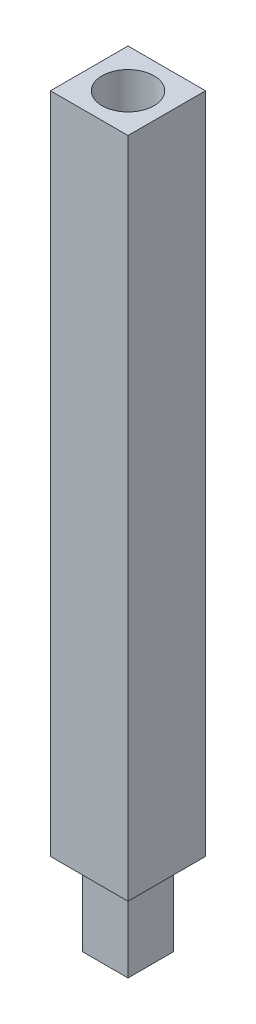
from build123d import *

# Parameters (mm, degrees)
SKETCH1_W           = 11.938
SKETCH1_H           = 11.938
BOSS_EXTRUDE1_DEPTH = 213.106
SKETCH3_R           = 3.68046
BOSS_EXTRUDE3_DEPTH = 28.575
SKETCH5_R           = 9.137508411
CUT_EXTRUDE1_DEPTH  = 139.573
SKETCH6_W           = 7.0104
SKETCH6_H           = 7.0104
BOSS_EXTRUDE5_DEPTH = 12.7
SKETCH2_R           = 4.0005
CUT_EXTRUDE2_DEPTH  = 11.1125


with BuildPart() as part:
    # Sketch1 → Boss-Extrude1 (new body)
    with BuildSketch(Plane(origin=(0, 0, 0), x_dir=(1, 0, 0), z_dir=(0, 1, 0))):
        Rectangle(SKETCH1_W, SKETCH1_H)
    extrude(amount=BOSS_EXTRUDE1_DEPTH)

    # Sketch3 → Boss-Extrude3 (add)
    with BuildSketch(Plane(origin=(0, 0, 0), x_dir=(-1, 0, 0), z_dir=(0, -1, 0))):
        Circle(SKETCH3_R)
    extrude(amount=BOSS_EXTRUDE3_DEPTH)

    # Sketch5 → Cut-Extrude1 (cut)
    with BuildSketch(Plane(origin=(0, -28.575, 0), x_dir=(-1, 0, 0), z_dir=(0, -1, 0))):
        Circle(SKETCH5_R)
    extrude(amount=-CUT_EXTRUDE1_DEPTH, mode=Mode.SUBTRACT)

    # Sketch6 → Boss-Extrude5 (add)
    with BuildSketch(Plane(origin=(0, 110.998, 0), x_dir=(-1, 0, 0), z_dir=(0, -1, 0))):
        Rectangle(SKETCH6_W, SKETCH6_H)
    extrude(amount=BOSS_EXTRUDE5_DEPTH)

    # Sketch2 → Cut-Extrude2 (cut)
    with BuildSketch(Plane(origin=(0, 213.106, 0), x_dir=(1, 0, 0), z_dir=(0, 1, 0))):
        Circle(SKETCH2_R)
    extrude(amount=-CUT_EXTRUDE2_DEPTH, mode=Mode.SUBTRACT)


solid = part.part
